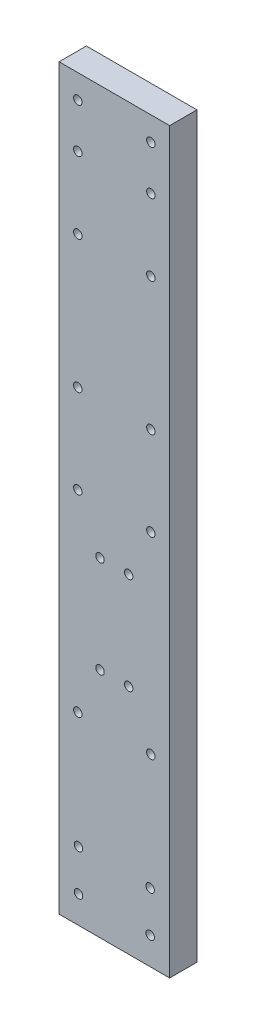
from build123d import *

# Parameters (mm, degrees)
SKETCH1_W           = 16.2
SKETCH1_H           = 108.14
SKETCH1_R           = 0.62
BOSS_EXTRUDE1_DEPTH = 4


with BuildPart() as part:
    # Sketch1 → Boss-Extrude1 (new body)
    with BuildSketch(Plane.XY):
        with Locations((8.1, 54.07)):
            Rectangle(SKETCH1_W, SKETCH1_H)
        with Locations((13.45, 55.21)):
            Circle(SKETCH1_R, mode=Mode.SUBTRACT)
        with Locations((10.2, 48.21)):
            Circle(SKETCH1_R, mode=Mode.SUBTRACT)
        with Locations((13.45, 104.66)):
            Circle(SKETCH1_R, mode=Mode.SUBTRACT)
        with Locations((2.75, 98.16)):
            Circle(SKETCH1_R, mode=Mode.SUBTRACT)
        with Locations((6, 48.21)):
            Circle(SKETCH1_R, mode=Mode.SUBTRACT)
        with Locations((2.75, 27)):
            Circle(SKETCH1_R, mode=Mode.SUBTRACT)
        with Locations((2.75, 87.66)):
            Circle(SKETCH1_R, mode=Mode.SUBTRACT)
        with Locations((2.75, 55.21)):
            Circle(SKETCH1_R, mode=Mode.SUBTRACT)
        with Locations((13.45, 87.66)):
            Circle(SKETCH1_R, mode=Mode.SUBTRACT)
        with Locations((13.45, 98.16)):
            Circle(SKETCH1_R, mode=Mode.SUBTRACT)
        with Locations((13.45, 68.21)):
            Circle(SKETCH1_R, mode=Mode.SUBTRACT)
        with Locations((6, 34)):
            Circle(SKETCH1_R, mode=Mode.SUBTRACT)
        with Locations((2.75, 104.66)):
            Circle(SKETCH1_R, mode=Mode.SUBTRACT)
        with Locations((10.2, 34)):
            Circle(SKETCH1_R, mode=Mode.SUBTRACT)
        with Locations((2.75, 68.21)):
            Circle(SKETCH1_R, mode=Mode.SUBTRACT)
        with Locations((13.45, 27)):
            Circle(SKETCH1_R, mode=Mode.SUBTRACT)
        with Locations((2.85, 10)):
            Circle(SKETCH1_R, mode=Mode.SUBTRACT)
        with Locations((13.35, 10)):
            Circle(SKETCH1_R, mode=Mode.SUBTRACT)
        with Locations((13.35, 4)):
            Circle(SKETCH1_R, mode=Mode.SUBTRACT)
        with Locations((2.85, 4)):
            Circle(SKETCH1_R, mode=Mode.SUBTRACT)
    extrude(amount=BOSS_EXTRUDE1_DEPTH)


solid = part.part
